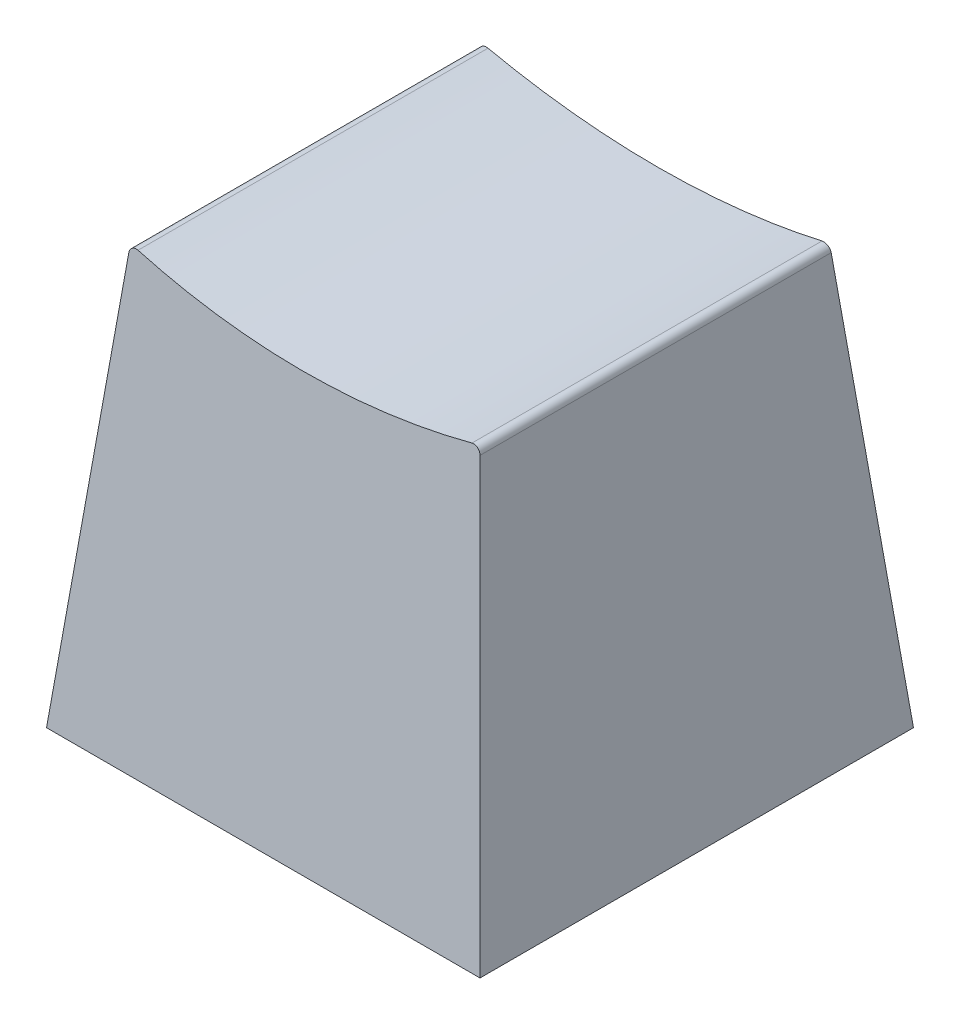
from build123d import *

# Parameters (mm, degrees)
SKETCH2_W               = 12.7
SKETCH2_H               = 12.7
SKETCH1_W               = 15.748
SKETCH1_H               = 15.748
CUT_EXTRUDE1_DEPTH      = 8.8740001
CUT_EXTRUDE1_DEPTH_BACK = 8.8740001
FILLET1_R               = 0.254


with BuildPart() as part:
    # Sketch2 → Loft1 section 0
    with BuildSketch(Plane(origin=(0, 15.24, 0), x_dir=(1, 0, 0), z_dir=(0, 1, 0))):
        Rectangle(SKETCH2_W, SKETCH2_H)
    # Sketch1 → Loft1 section 1
    with BuildSketch(Plane(origin=(0, 0, 0), x_dir=(1, 0, 0), z_dir=(0, 1, 0))):
        Rectangle(SKETCH1_W, SKETCH1_H)
    loft()

    # Sketch3 → Cut-Extrude1 (cut, two sides)
    with BuildSketch(Plane.XY) as cut_extrude1_sk:
        with BuildLine():
            Line((-56.40168157, 28.163288611), (-6.35, 15.24))
            ThreePointArc((-6.35, 15.24), (0, 14.433444248), (6.35, 15.24))
            Line((6.35, 15.24), (56.40168157, 28.163288611))
            Line((56.40168157, 28.163288611), (56.40168157, 131.549597501))
            Line((56.40168157, 131.549597501), (-56.40168157, 131.549597501))
            Line((-56.40168157, 131.549597501), (-56.40168157, 28.163288611))
        make_face()
    extrude(amount=CUT_EXTRUDE1_DEPTH, mode=Mode.SUBTRACT)
    extrude(cut_extrude1_sk.sketch, amount=-CUT_EXTRUDE1_DEPTH_BACK, mode=Mode.SUBTRACT)

    # Fillet1
    fillet1_edges = [part.edges().sort_by_distance(p)[0] for p in [
        (6.35, 15.24, 0),
        (-6.35, 15.24, 0),
    ]]
    fillet(fillet1_edges, radius=FILLET1_R)


solid = part.part
